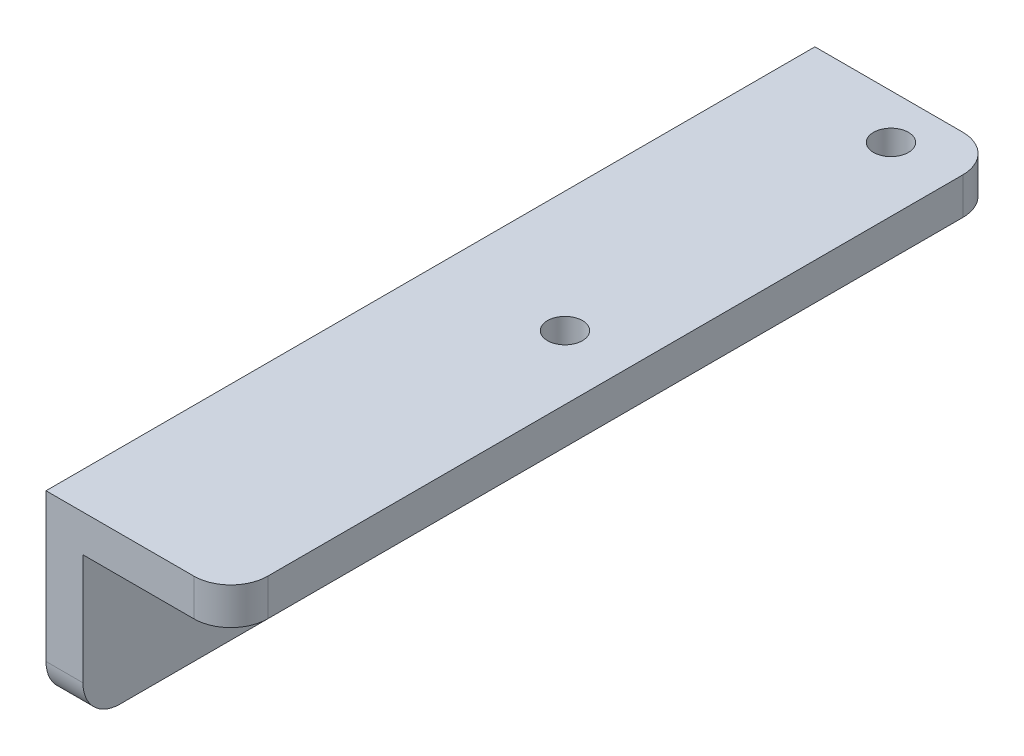
from build123d import *

# Parameters (mm, degrees)
BOSS_EXTRUDE1_DEPTH = 66.04
SKETCH2_R           = 2.5
CUT_EXTRUDE1_DEPTH  = 4.175
BOSS_EXTRUDE2_DEPTH = 2.54
SKETCH4_W           = 3.175
SKETCH4_H           = 7.62
CUT_EXTRUDE2_DEPTH  = 25.4
SKETCH5_R           = 1.5
CUT_EXTRUDE3_DEPTH  = 25.4
FILLET1_R           = 3.175


with BuildPart() as part:
    # Sketch1 → Boss-Extrude1 (new body)
    with BuildSketch(Plane.XY):
        Polygon((3.175, -3.175), (15.875, -3.175), (15.875, 0), (0, 0), (0, -15.875), (3.175, -15.875), align=None)
    extrude(amount=-BOSS_EXTRUDE1_DEPTH)

    # Sketch2 → Cut-Extrude1 (cut, through all)
    with BuildSketch(Plane(origin=(3.175, 0, 0), x_dir=(0, 0, -1), z_dir=(1, 0, 0))):
        with Locations((29.95, -9.525)):
            Circle(SKETCH2_R)
        with Locations((9.95, -9.525)):
            Circle(SKETCH2_R)
    extrude(amount=-CUT_EXTRUDE1_DEPTH, mode=Mode.SUBTRACT)

    # Sketch3 → Boss-Extrude2 (add, symmetric)
    with BuildSketch(Plane.XY.offset(-19.685)):
        Polygon((3.175, -15.875), (3.175, -3.175), (15.875, -3.175), align=None)
    extrude(amount=BOSS_EXTRUDE2_DEPTH, both=True)

    # Sketch4 → Cut-Extrude2 (cut)
    with BuildSketch(Plane(origin=(0, 0, -66.04), x_dir=(-1, 0, 0), z_dir=(0, 0, -1))):
        with Locations((-1.5875, -12.065)):
            Rectangle(SKETCH4_W, SKETCH4_H)
    extrude(amount=-CUT_EXTRUDE2_DEPTH, mode=Mode.SUBTRACT)

    # Sketch5 → Cut-Extrude3 (cut)
    with BuildSketch(Plane.XZ.offset(3.175)):
        with Locations((10.375, -34.196688578)):
            Circle(SKETCH5_R)
        with Locations((10.375, -62.196688578)):
            Circle(SKETCH5_R)
    extrude(amount=-CUT_EXTRUDE3_DEPTH, mode=Mode.SUBTRACT)

    # Fillet1
    fillet1_edges = [part.edges().sort_by_distance(p)[0] for p in [
        (15.875, -1.5875, -66.04),
        (1.5875, -15.875, -40.64),
        (1.5875, -8.255, -66.04),
        (1.5875, -15.875, 0),
        (15.875, -1.5875, 0),
    ]]
    fillet(fillet1_edges, radius=FILLET1_R)


solid = part.part
